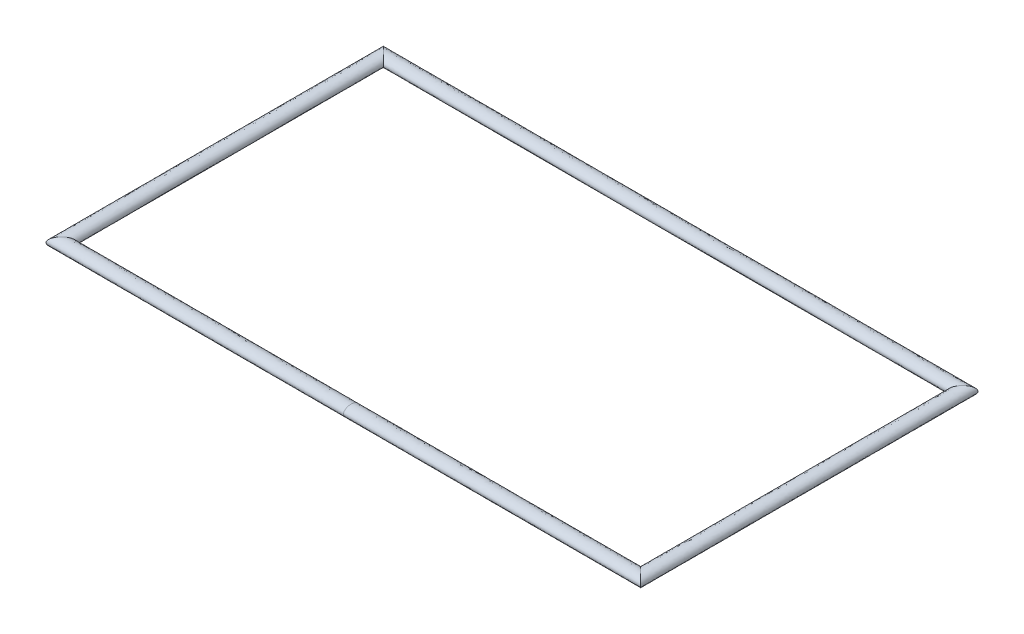
from build123d import *

# Parameters (mm, degrees)
SKIZZE9_RX = 1.15
SKIZZE9_RY = 0.75


with BuildPart() as part:
    # Austragung2: sweep along a path in Skizze2
    with BuildLine(Plane(origin=(0, 0, 0), x_dir=(1, 0, 0), z_dir=(0, 1, 0))) as austragung2_path:
        Line((-43.2, -24), (43.2, -24))
        Line((43.2, -24), (43.2, 24))
        Line((43.2, 24), (-43.2, 24))
        Line((-43.2, 24), (-43.2, -24))
    # Skizze9 → Austragung2 (sweep)
    with BuildSketch(Plane(origin=(0, 0, 0), x_dir=(0, 0, -1), z_dir=(1, 0, 0))):
        with Locations((-24, 0)):
            Ellipse(SKIZZE9_RX, SKIZZE9_RY)
    sweep(path=austragung2_path.line, transition=Transition.RIGHT)


solid = part.part
